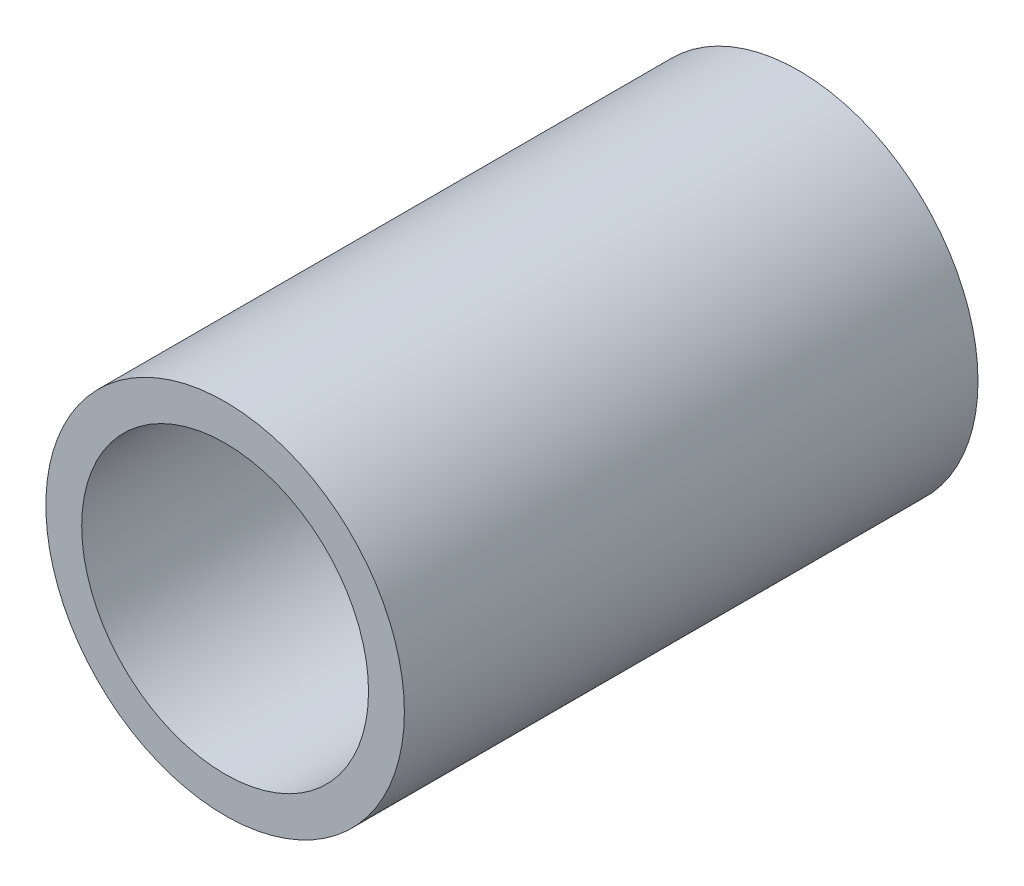
from build123d import *

# Parameters (mm, degrees)
SKETCH1_R           = 15.875
SKETCH1_R_2         = 12.7
BOSS_EXTRUDE1_DEPTH = 50.8


with BuildPart() as part:
    # Sketch1 → Boss-Extrude1 (new body)
    with BuildSketch(Plane.XY):
        Circle(SKETCH1_R)
        Circle(SKETCH1_R_2, mode=Mode.SUBTRACT)
    extrude(amount=BOSS_EXTRUDE1_DEPTH)


solid = part.part
